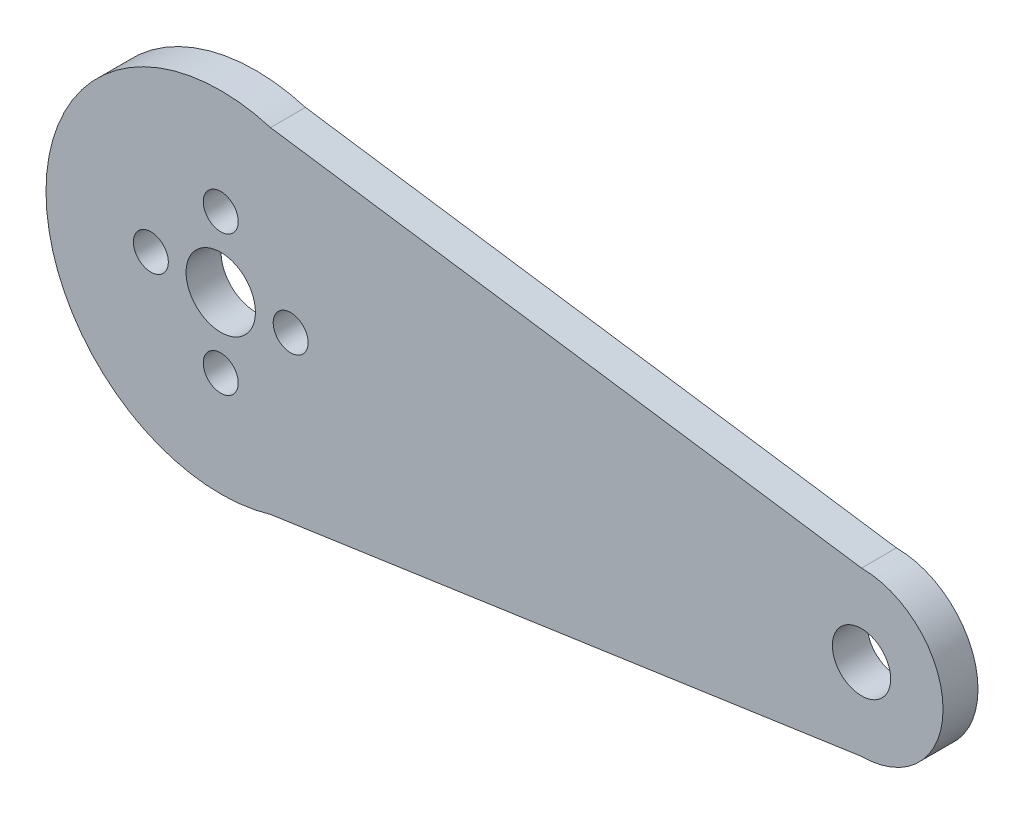
from build123d import *

# Parameters (mm, degrees)
SKETCH1_R           = 15
SKETCH1_R_2         = 2.976854353
SKETCH1_R_3         = 1.5
BOSS_EXTRUDE1_DEPTH = 3
SKETCH2_R           = 2.5
BOSS_EXTRUDE2_DEPTH = 3


with BuildPart() as part:
    # Sketch1 → Boss-Extrude1 (new body)
    with BuildSketch(Plane.XY):
        with Locations((-0.759875944, 7.250482965)):
            Circle(SKETCH1_R)
        with Locations((-0.759875944, 7.250482965)):
            Circle(SKETCH1_R_2, mode=Mode.SUBTRACT)
        with Locations((-0.759875944, 13.250482965)):
            Circle(SKETCH1_R_3, mode=Mode.SUBTRACT)
        with Locations((-6.759875944, 7.250482965)):
            Circle(SKETCH1_R_3, mode=Mode.SUBTRACT)
        with Locations((-0.759875944, 1.250482965)):
            Circle(SKETCH1_R_3, mode=Mode.SUBTRACT)
        with Locations((5.240124056, 7.250482965)):
            Circle(SKETCH1_R_3, mode=Mode.SUBTRACT)
    extrude(amount=BOSS_EXTRUDE1_DEPTH)

    # Sketch2 → Boss-Extrude2 (add)
    with BuildSketch(Plane.XY.offset(3)):
        with BuildLine():
            Line((-0.759875944, 22.250482965), (54.240124056, 14.250482965))
            ThreePointArc((54.240124056, 14.250482965), (61.240124056, 7.250482965), (54.240124056, 0.250482965))
            Line((54.240124056, 0.250482965), (-0.759875944, -7.749517035))
            ThreePointArc((-0.759875944, -7.749517035), (8.423325109, 7.250482965), (-0.759875944, 22.250482965))
        make_face()
        with Locations((54.240124056, 7.250482965)):
            Circle(SKETCH2_R, mode=Mode.SUBTRACT)
    extrude(amount=-BOSS_EXTRUDE2_DEPTH)


solid = part.part
